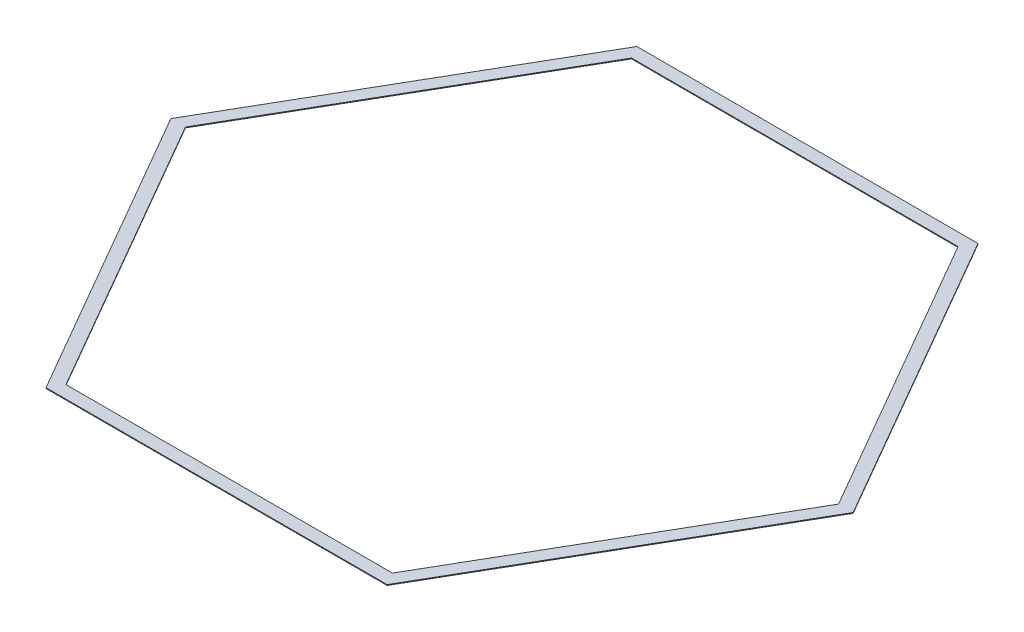
from build123d import *

# Parameters (mm, degrees)
BOSS_EXTRUDE1_DEPTH = 3.175


with BuildPart() as part:
    # Sketch1 → Boss-Extrude1 (new body)
    with BuildSketch(Plane(origin=(0, 0, 0), x_dir=(1, 0, 0), z_dir=(0, 1, 0))):
        Polygon((-685.509319248, 1187.33697), (-1371.018638497, 0), (-685.509319248, -1187.33697), (685.509319248, -1187.33697), (1371.018638497, 0), (685.509319248, 1187.33697), align=None)
        Polygon((1312.359851147, 0), (656.179925573, 1136.53697), (-656.179925573, 1136.53697), (-1312.359851147, 0), (-656.179925573, -1136.53697), (656.179925573, -1136.53697), align=None, mode=Mode.SUBTRACT)
    extrude(amount=BOSS_EXTRUDE1_DEPTH)


solid = part.part
